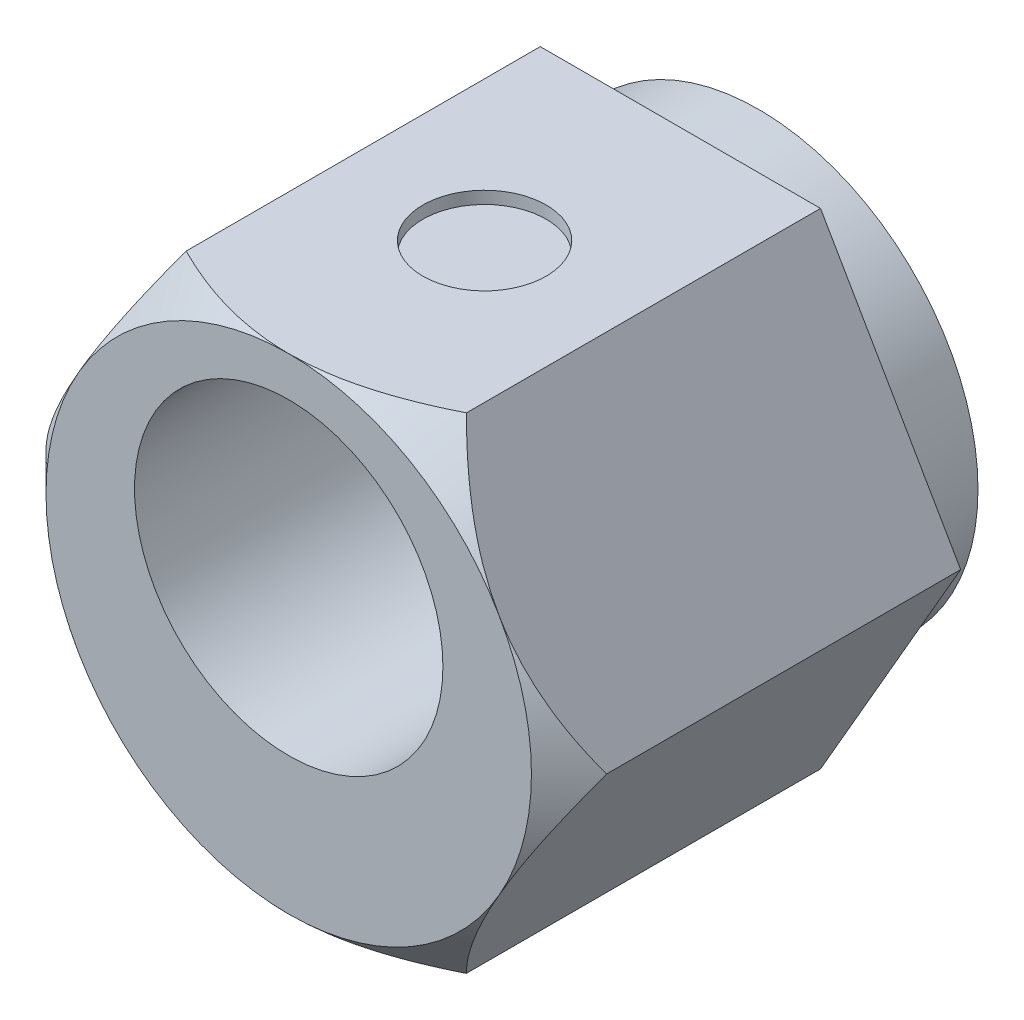
from build123d import *

# Parameters (mm, degrees)
SKETCH1_R      = 3.555
EXTRUDE1_DEPTH = 1.27
ICE1_DEPTH     = 6.35
SKETCH3_R      = 2.5
ICE2_DEPTH     = 8.62
SKETCH4_R      = 1
ICE3_DEPTH     = 0.2


with BuildPart() as part:
    # Sketch1 → Extrude1 (new body)
    with BuildSketch(Plane.XY):
        Circle(SKETCH1_R)
    extrude(amount=-EXTRUDE1_DEPTH)

    # Sketch2 → ICE1 (add)
    with BuildSketch(Plane.XY):
        Polygon((4.543746619, 0), (2.271873309, 3.935), (-2.271873309, 3.935), (-4.543746619, 0), (-2.271873309, -3.935), (2.271873309, -3.935), align=None)
    extrude(amount=ICE1_DEPTH)

    # Sketch3 → ICE2 (cut, through all)
    with BuildSketch(Plane.XY.offset(6.35)):
        with Locations((0, 0.79)):
            Circle(SKETCH3_R)
    extrude(amount=-ICE2_DEPTH, mode=Mode.SUBTRACT)

    # Sketch4 → ICE3 (cut)
    with BuildSketch(Plane(origin=(0, 3.935, 0), x_dir=(1, 0, 0), z_dir=(0, 1, 0))):
        with Locations((0, -3.175)):
            Circle(SKETCH4_R)
    extrude(amount=-ICE3_DEPTH, mode=Mode.SUBTRACT)

    # Sketch5 → RevCut1 (revolve, cut)
    with BuildSketch(Plane(origin=(0, 0, 0), x_dir=(-0.866025404, -0.5, 0), z_dir=(-0.5, 0.866025404, 0))):
        Polygon((-3.935, 6.35), (-10.285, 0), (-10.285, 6.35), align=None)
    revolve(axis=Axis((0, 0, 0), (0, 0, 1)), mode=Mode.SUBTRACT)


solid = part.part
